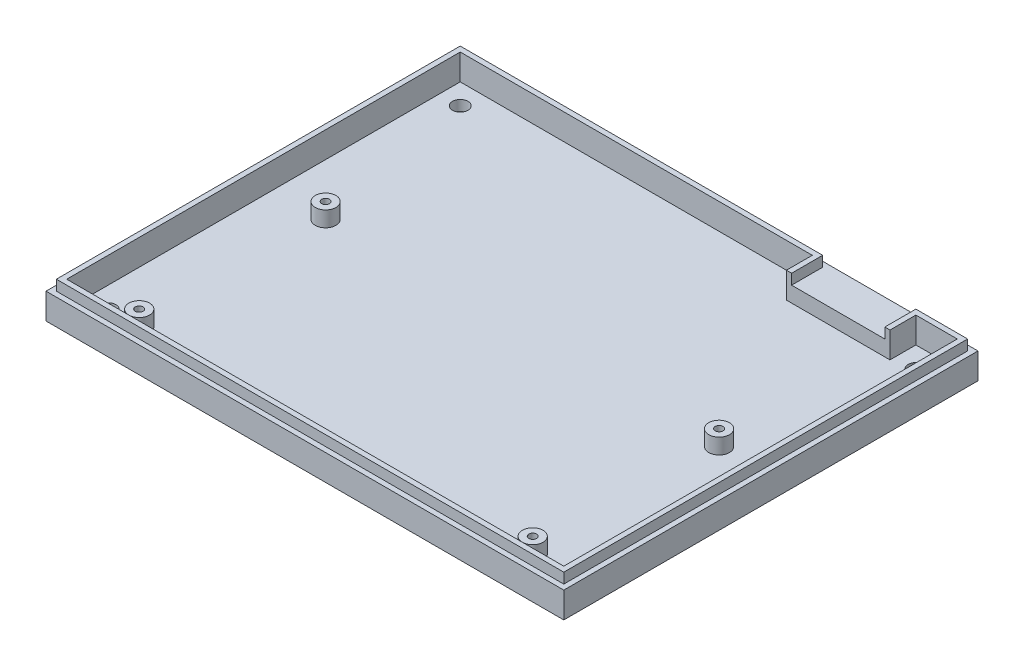
from build123d import *

# Parameters (mm, degrees)
ESQUISSE1_W             = 100
ESQUISSE1_H             = 80
BOSS_EXTRU_1_DEPTH      = 2
ESQUISSE2_W             = 100
ESQUISSE2_H             = 80
ESQUISSE2_W_2           = 96
ESQUISSE2_H_2           = 76
ESQUISSE2_R             = 2
BOSS_EXTRU_2_DEPTH      = 3
ESQUISSE3_R             = 0.75
ENL_V_MAT_EXTRU_1_DEPTH = 5
ESQUISSE4_R             = 1.5
ENL_V_MAT_EXTRU_2_DEPTH = 5
ESQUISSE5_W             = 98
ESQUISSE5_H             = 78
ESQUISSE5_W_2           = 96
ESQUISSE5_H_2           = 76
BOSS_EXTRU_3_DEPTH      = 2
ESQUISSE6_W             = 20
ESQUISSE6_H             = 5
BOSS_EXTRU_4_DEPTH      = 3
ESQUISSE7_W             = 1
ESQUISSE7_H             = 5
BOSS_EXTRU_5_DEPTH      = 2
ESQUISSE8_W             = 18
ESQUISSE8_H             = 2
ENL_V_MAT_EXTRU_3_DEPTH = 2


with BuildPart() as part:
    # Esquisse1 → Boss.-Extru.1 (new body)
    with BuildSketch(Plane(origin=(0, 0, 0), x_dir=(1, 0, 0), z_dir=(0, 1, 0))):
        Rectangle(ESQUISSE1_W, ESQUISSE1_H)
    extrude(amount=BOSS_EXTRU_1_DEPTH)

    # Esquisse2 → Boss.-Extru.2 (add)
    with BuildSketch(Plane(origin=(0, 2, 0), x_dir=(1, 0, 0), z_dir=(0, 1, 0))):
        Rectangle(ESQUISSE2_W, ESQUISSE2_H)
        Rectangle(ESQUISSE2_W_2, ESQUISSE2_H_2, mode=Mode.SUBTRACT)
        with Locations((38, -34)):
            Circle(ESQUISSE2_R)
        with Locations((38, 2)):
            Circle(ESQUISSE2_R)
        with Locations((-38, -34)):
            Circle(ESQUISSE2_R)
        with Locations((-38, 2)):
            Circle(ESQUISSE2_R)
    extrude(amount=BOSS_EXTRU_2_DEPTH)

    # Esquisse3 → Enlèv. mat.-Extru.1 (cut)
    with BuildSketch(Plane(origin=(0, 5, 0), x_dir=(1, 0, 0), z_dir=(0, 1, 0))):
        with Locations((-38, 2)):
            Circle(ESQUISSE3_R)
        with Locations((-38, -34)):
            Circle(ESQUISSE3_R)
        with Locations((38, 2)):
            Circle(ESQUISSE3_R)
        with Locations((38, -34)):
            Circle(ESQUISSE3_R)
    extrude(amount=-ENL_V_MAT_EXTRU_1_DEPTH, mode=Mode.SUBTRACT)

    # Esquisse4 → Enlèv. mat.-Extru.2 (cut)
    with BuildSketch(Plane(origin=(0, 2, 0), x_dir=(1, 0, 0), z_dir=(0, 1, 0))):
        with Locations((-44, 34)):
            Circle(ESQUISSE4_R)
        with Locations((44, 34)):
            Circle(ESQUISSE4_R)
        with Locations((44, -34)):
            Circle(ESQUISSE4_R)
        with Locations((-44, -34)):
            Circle(ESQUISSE4_R)
    extrude(amount=-ENL_V_MAT_EXTRU_2_DEPTH, mode=Mode.SUBTRACT)

    # Esquisse5 → Boss.-Extru.3 (add)
    with BuildSketch(Plane(origin=(0, 5, 0), x_dir=(1, 0, 0), z_dir=(0, 1, 0))):
        Rectangle(ESQUISSE5_W, ESQUISSE5_H)
        Rectangle(ESQUISSE5_W_2, ESQUISSE5_H_2, mode=Mode.SUBTRACT)
    extrude(amount=BOSS_EXTRU_3_DEPTH)

    # Esquisse6 → Boss.-Extru.4 (add)
    with BuildSketch(Plane(origin=(0, 2, 0), x_dir=(1, 0, 0), z_dir=(0, 1, 0))):
        with Locations((30, 35.5)):
            Rectangle(ESQUISSE6_W, ESQUISSE6_H)
    extrude(amount=BOSS_EXTRU_4_DEPTH)

    # Esquisse7 → Boss.-Extru.5 (add)
    with BuildSketch(Plane(origin=(0, 5, 0), x_dir=(1, 0, 0), z_dir=(0, 1, 0))):
        with Locations((20.5, 35.5)):
            Rectangle(ESQUISSE7_W, ESQUISSE7_H)
        with Locations((39.5, 35.5)):
            Rectangle(ESQUISSE7_W, ESQUISSE7_H)
    extrude(amount=BOSS_EXTRU_5_DEPTH)

    # Esquisse8 → Enlèv. mat.-Extru.3 (cut)
    with BuildSketch(Plane.XY.offset(-38)):
        with Locations((30, 6)):
            Rectangle(ESQUISSE8_W, ESQUISSE8_H)
    extrude(amount=-ENL_V_MAT_EXTRU_3_DEPTH, mode=Mode.SUBTRACT)


solid = part.part
